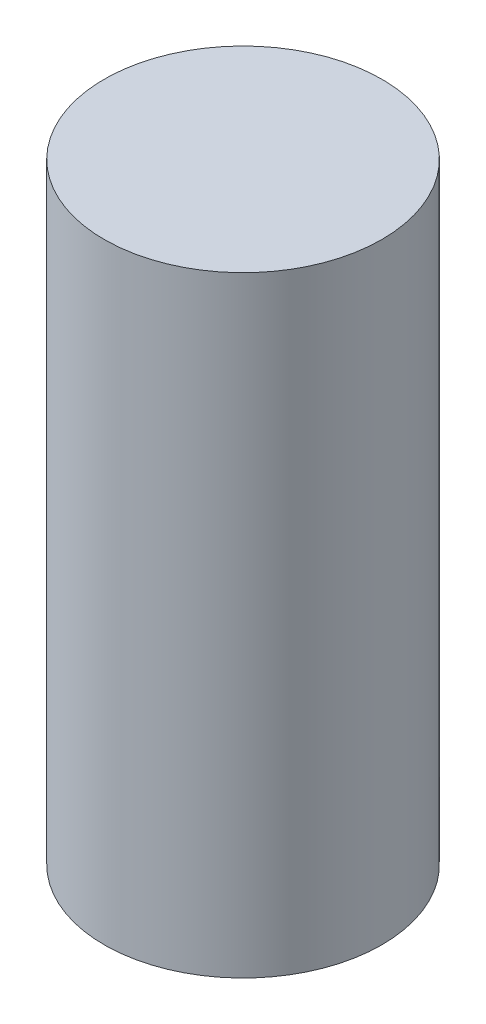
from build123d import *

# Parameters (mm, degrees)
SKETCH1_W = 8.255
SKETCH1_H = 36.322


with BuildPart() as part:
    # Sketch1 → Revolve1 (revolve)
    with BuildSketch(Plane.XY):
        with Locations((-4.1275, 0)):
            Rectangle(SKETCH1_W, SKETCH1_H)
    revolve(axis=Axis((0, 18.161, 0), (0, 1, 0)))


solid = part.part
